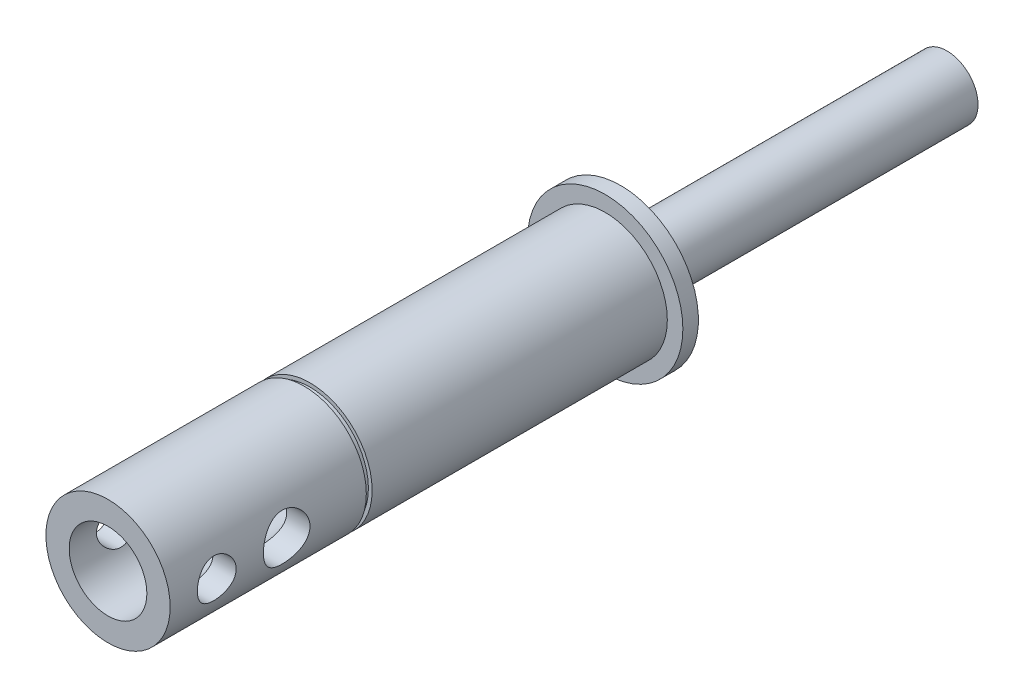
from build123d import *

# Parameters (mm, degrees)
SKETCH1_R          = 15.875
RAWSTOCK_DEPTH     = 194.6402
SKETCH10_R         = 12.7
FACINGOP_DEPTH     = 23.1902
RELIEFHOLE_D       = 12.7
RELIEFHOLE_DEPTH   = 92.075
RELIEFHOLE_TIP     = 3.815464931
WIRESHOLE_D        = 15.875
WIRESHOLE_DEPTH    = 115.2652
WIRESHOLE_TIP      = 4.769331164
SKETCH6_OUTSIDE_W  = 73.7
SKETCH6_OUTSIDE_H  = 73.7
SKETCH6_OUTSIDE_R  = 12.7
SHAFTDIAM_DEPTH    = 124.7902
SKETCH7_OUTSIDE_W  = 69.196
SKETCH7_OUTSIDE_H  = 69.196
SKETCH7_OUTSIDE_R  = 11.938
GROOVE_DEPTH       = 1.190625
SKETCH8_OUTSIDE_W  = 69.196
SKETCH8_OUTSIDE_H  = 69.196
SKETCH8_OUTSIDE_R  = 6.35
ENCODERSHAFT_DEPTH = 66.675
SKETCH12_R         = 3.96875
SKETCH12_R_2       = 4.7625
HOLES_TOP_DEPTH    = 29.575
SLIPRINGHOLE_D     = 4.7625
SLIPRINGHOLE_DEPTH = 25.4
SLIPRINGHOLE_TIP   = 1.430799349


with BuildPart() as part:
    # Sketch1 → RawStock (new body)
    with BuildSketch(Plane.XY):
        Circle(SKETCH1_R)
    extrude(amount=RAWSTOCK_DEPTH)

    # Sketch10 → FacingOp (cut)
    with BuildSketch(Plane.XY.offset(194.6402)):
        Circle(SKETCH10_R)
    extrude(amount=-FACINGOP_DEPTH, mode=Mode.SUBTRACT)

    # ReliefHole
    with Locations(Plane.XY.offset(194.6402)):
        with Locations((0, 0)):
            Hole(RELIEFHOLE_D / 2, depth=RELIEFHOLE_DEPTH)
            with Locations((0, 0, -(RELIEFHOLE_DEPTH + RELIEFHOLE_TIP / 2))):  # 118° drill point
                Cone(0, RELIEFHOLE_D / 2, RELIEFHOLE_TIP, mode=Mode.SUBTRACT)

    # WiresHole
    with Locations(Plane.XY.offset(194.6402)):
        with Locations((0, 0)):
            Hole(WIRESHOLE_D / 2, depth=WIRESHOLE_DEPTH)
            with Locations((0, 0, -(WIRESHOLE_DEPTH + WIRESHOLE_TIP / 2))):  # 118° drill point
                Cone(0, WIRESHOLE_D / 2, WIRESHOLE_TIP, mode=Mode.SUBTRACT)

    # Sketch6 outside → ShaftDiam (cut)
    with BuildSketch(Plane.XY.offset(194.6402)):
        Rectangle(SKETCH6_OUTSIDE_W, SKETCH6_OUTSIDE_H)
        Circle(SKETCH6_OUTSIDE_R, mode=Mode.SUBTRACT)
    extrude(amount=-SHAFTDIAM_DEPTH, mode=Mode.SUBTRACT)

    # Sketch7 outside → Groove (cut)
    with BuildSketch(Plane.XY.offset(130.175)):
        Rectangle(SKETCH7_OUTSIDE_W, SKETCH7_OUTSIDE_H)
        Circle(SKETCH7_OUTSIDE_R, mode=Mode.SUBTRACT)
    extrude(amount=GROOVE_DEPTH, mode=Mode.SUBTRACT)

    # Sketch8 outside → EncoderShaft (cut)
    with BuildSketch(Plane(origin=(0, 0, 0), x_dir=(-1, 0, 0), z_dir=(0, 0, -1))):
        Rectangle(SKETCH8_OUTSIDE_W, SKETCH8_OUTSIDE_H)
        Circle(SKETCH8_OUTSIDE_R, mode=Mode.SUBTRACT)
    extrude(amount=-ENCODERSHAFT_DEPTH, mode=Mode.SUBTRACT)

    # Sketch12 → Holes_Top (cut, through all)
    with BuildSketch(Plane(origin=(-12.7, 0, 0), x_dir=(0, 1, 0), z_dir=(-1, 0, 0))):
        with Locations((0, -161.925)):
            Circle(SKETCH12_R)
        with Locations((0, -147.6375)):
            Circle(SKETCH12_R_2)
    extrude(amount=-HOLES_TOP_DEPTH, mode=Mode.SUBTRACT)

    # SlipRingHole
    with Locations(Plane(origin=(0, 0, 66.675), x_dir=(-1, 0, 0), z_dir=(0, 0, -1))):
        with Locations((0, -8.73125)):
            Hole(SLIPRINGHOLE_D / 2, depth=SLIPRINGHOLE_DEPTH)
            with Locations((0, 0, -(SLIPRINGHOLE_DEPTH + SLIPRINGHOLE_TIP / 2))):  # 118° drill point
                Cone(0, SLIPRINGHOLE_D / 2, SLIPRINGHOLE_TIP, mode=Mode.SUBTRACT)


solid = part.part
